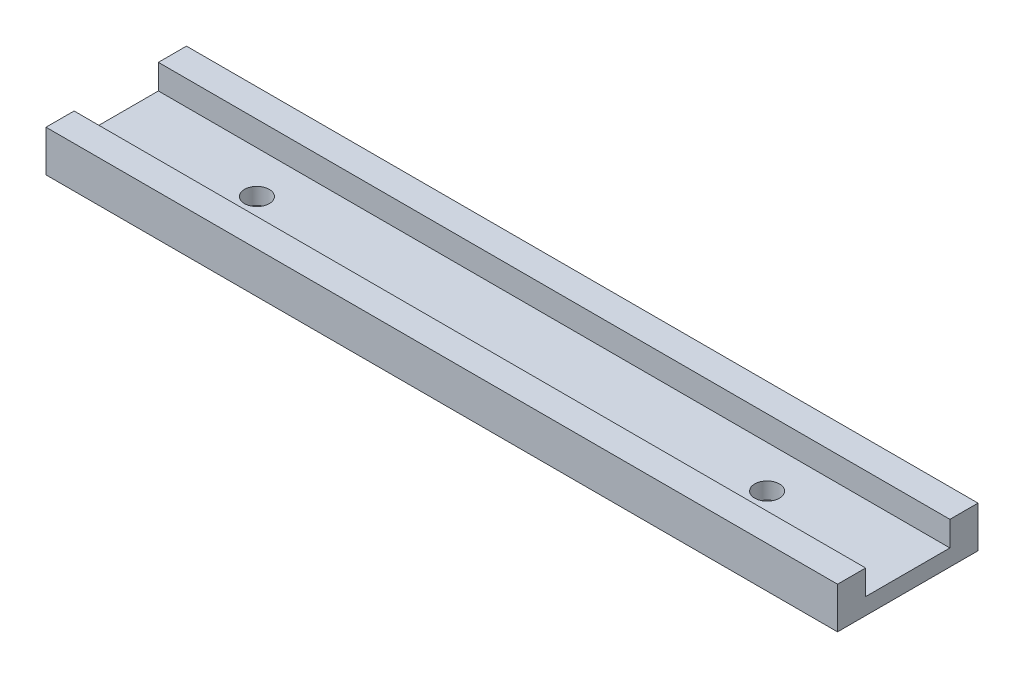
from build123d import *

# Parameters (mm, degrees)
BOSS_EXTRUDE1_DEPTH       = 47.9
F_3_0MM_DOWEL_HOLE1_D     = 3
F_3_0MM_DOWEL_HOLE1_DEPTH = 8.5
F_3_0MM_DOWEL_HOLE1_TIP   = 0.901290929


with BuildPart() as part:
    # Sketch1 → Boss-Extrude1 (new body, symmetric)
    with BuildSketch(Plane(origin=(0, 0, 0), x_dir=(0, 0, -1), z_dir=(1, 0, 0))):
        Polygon((-8.5, 0), (8.5, 0), (8.5, 5), (5.1, 5), (5.1, 2), (-5.1, 2), (-5.1, 5), (-8.5, 5), align=None)
    extrude(amount=BOSS_EXTRUDE1_DEPTH, both=True)

    # Ø3.0mm Dowel Hole1
    with Locations(Plane(origin=(0, 2, 0), x_dir=(1, 0, 0), z_dir=(0, 1, 0))):
        with Locations((-30.875, 0), (30.875, 0)):
            Hole(F_3_0MM_DOWEL_HOLE1_D / 2, depth=F_3_0MM_DOWEL_HOLE1_DEPTH)
            with Locations((0, 0, -(F_3_0MM_DOWEL_HOLE1_DEPTH + F_3_0MM_DOWEL_HOLE1_TIP / 2))):  # 118° drill point
                Cone(0, F_3_0MM_DOWEL_HOLE1_D / 2, F_3_0MM_DOWEL_HOLE1_TIP, mode=Mode.SUBTRACT)


solid = part.part
